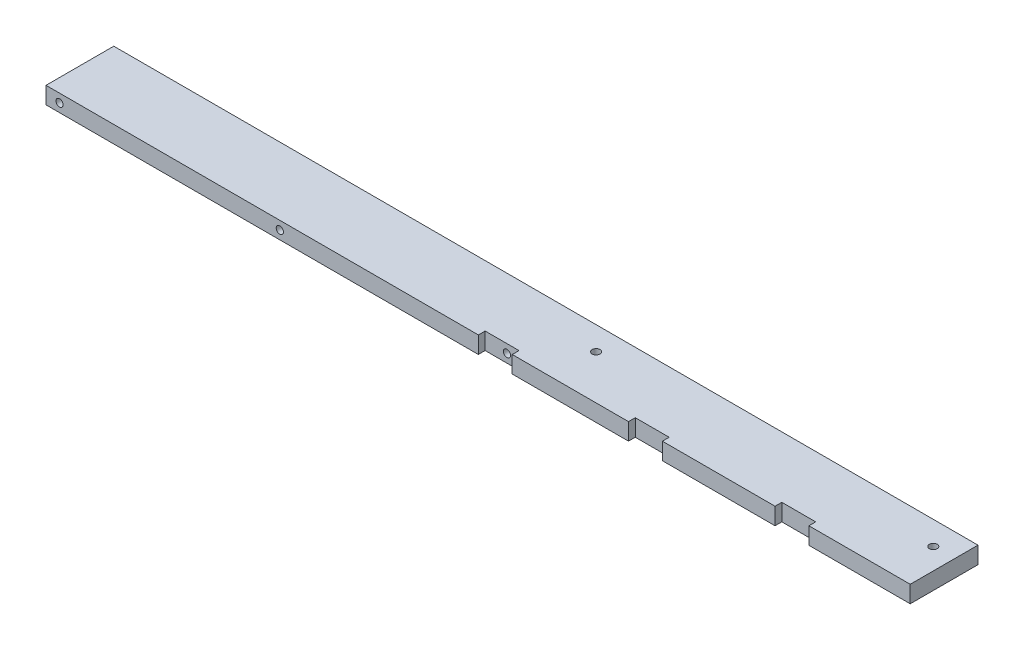
from build123d import *

# Parameters (mm, degrees)
SKETCH1_W                                           = 25.4
SKETCH1_H                                           = 6.35
BOSS_EXTRUDE1_DEPTH                                 = 323.85
TAP_DRILL_FOR_6_32_TAP1_D                           = 2.7051
CBORE_FOR_4_BINDING_HEAD_MACHINE_SCREW2_D           = 2.9464
CBORE_FOR_4_BINDING_HEAD_MACHINE_SCREW2_CBORE_D     = 4.8006
CBORE_FOR_4_BINDING_HEAD_MACHINE_SCREW2_CBORE_DEPTH = 2.8448
SKETCH7_W                                           = 16.52236986
SKETCH7_H                                           = 12.7
SKETCH7_W_2                                         = 15.385295506
CUT_EXTRUDE2_DEPTH                                  = 2.54


with BuildPart() as part:
    # Sketch1 → Boss-Extrude1 (new body)
    with BuildSketch(Plane(origin=(0, 0, 0), x_dir=(0, 0, -1), z_dir=(1, 0, 0))):
        with Locations((12.7, 3.175)):
            Rectangle(SKETCH1_W, SKETCH1_H)
    extrude(amount=BOSS_EXTRUDE1_DEPTH)

    # Tap Drill for #6-32 Tap1 (through all)
    with Locations(Plane.XY):
        with Locations((5.08, 3.175), (87.63, 3.175), (170.18, 3.175)):
            Hole(TAP_DRILL_FOR_6_32_TAP1_D / 2)

    # CBORE for #4 Binding Head Machine Screw2 (through all)
    with Locations(Plane(origin=(0, 0, 0), x_dir=(-1, 0, 0), z_dir=(0, -1, 0))):
        with Locations((-315.9125, 16.5862), (-189.5475, 16.5862)):
            CounterBoreHole(CBORE_FOR_4_BINDING_HEAD_MACHINE_SCREW2_D / 2, CBORE_FOR_4_BINDING_HEAD_MACHINE_SCREW2_CBORE_D / 2, CBORE_FOR_4_BINDING_HEAD_MACHINE_SCREW2_CBORE_DEPTH)

    # Sketch7 → Cut-Extrude2 (cut)
    with BuildSketch(Plane(origin=(405.672488364, 78.178033599, 0), x_dir=(0, 1, 0), z_dir=(0, 0, 1))):
        with Locations((-76.963648836, 237.306121416)):
            Rectangle(SKETCH7_W, SKETCH7_H)
        with Locations((-77.090648836, 181.04446618)):
            Rectangle(SKETCH7_W_2, SKETCH7_H)
        with Locations((-77.090648836, 126.129362211)):
            Rectangle(SKETCH7_W_2, SKETCH7_H)
    extrude(amount=-CUT_EXTRUDE2_DEPTH, mode=Mode.SUBTRACT)


solid = part.part
